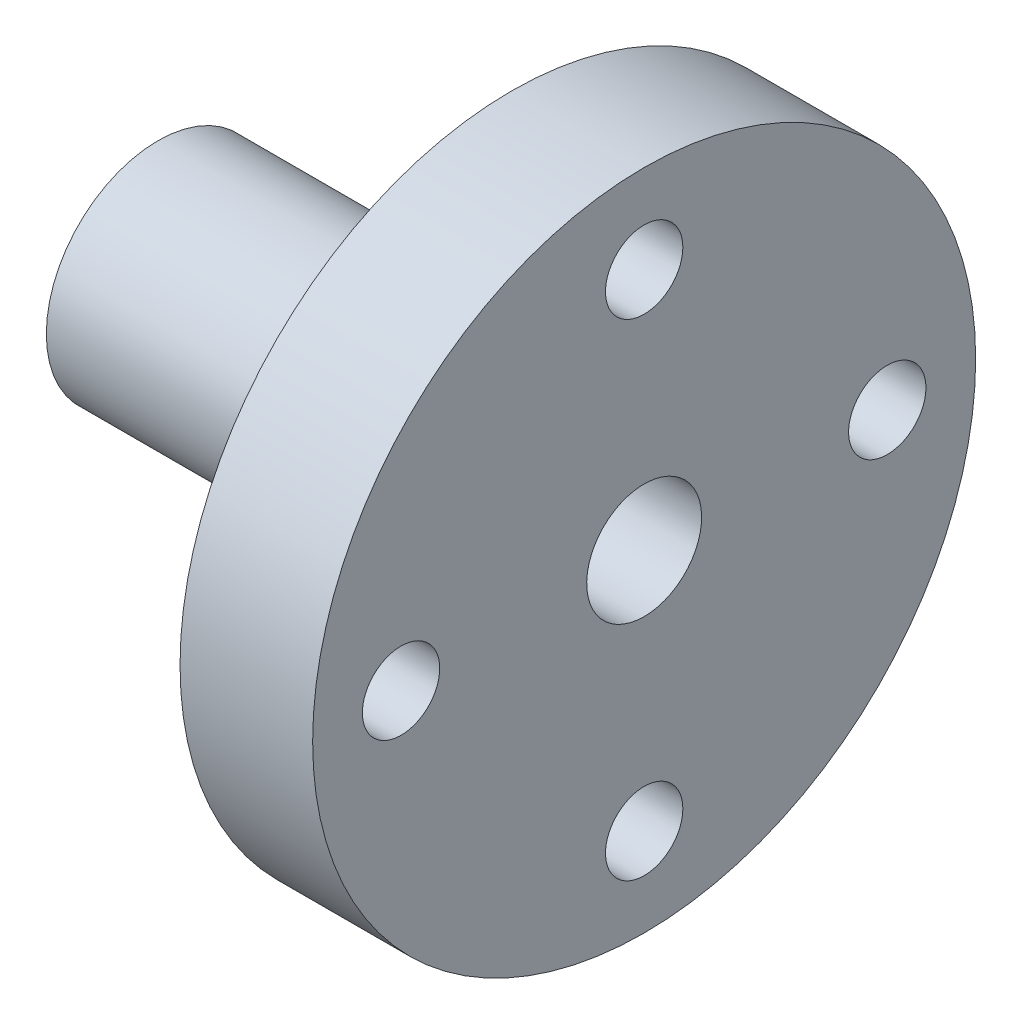
from build123d import *

# Parameters (mm, degrees)
ENL_V_MAT_EXTRU_1_REACH      = 24
ESQUISSE2_R                  = 1.75
ENL_V_MAT_EXTRU_2_DEPTH      = 10
R_P_TITION_CIRCULAIRE1_COUNT = 24


with BuildPart() as part:
    # Esquisse1 → Révolution1 (revolve)
    with BuildSketch(Plane.XY):
        Polygon((0, 2.25), (0, 5.05), (13, 5.05), (13, 8), (16, 8), (16, 15), (22, 15), (22, 2.6), (6, 2.6), (6, 1.2), (3, 1.2), (3, 2.25), align=None)
    revolve(axis=Axis((0, 0, 0), (1, 0, 0)))

    # Esquisse2 → Enlèv. mat.-Extru.1 (cut, up to next)
    with BuildSketch(Plane(origin=(22, 0, 0), x_dir=(0, 0, -1), z_dir=(1, 0, 0)), mode=Mode.PRIVATE) as enl_v_mat_extru_1_sk1:
        with Locations((0, 11)):
            Circle(ESQUISSE2_R)
    enl_v_mat_extru_1_tool1 = extrude(enl_v_mat_extru_1_sk1.sketch, amount=-ENL_V_MAT_EXTRU_1_REACH, mode=Mode.PRIVATE) & part.part
    add(enl_v_mat_extru_1_tool1.solids().sort_by_distance((22, 11, 0))[0], mode=Mode.SUBTRACT)
    # Esquisse2 → Enlèv. mat.-Extru.1 (cut, up to next)
    with BuildSketch(Plane(origin=(22, 0, 0), x_dir=(0, 0, -1), z_dir=(1, 0, 0)), mode=Mode.PRIVATE) as enl_v_mat_extru_1_sk2:
        with Locations((11, 0)):
            Circle(ESQUISSE2_R)
    enl_v_mat_extru_1_tool2 = extrude(enl_v_mat_extru_1_sk2.sketch, amount=-ENL_V_MAT_EXTRU_1_REACH, mode=Mode.PRIVATE) & part.part
    add(enl_v_mat_extru_1_tool2.solids().sort_by_distance((22, 0, -11))[0], mode=Mode.SUBTRACT)
    # Esquisse2 → Enlèv. mat.-Extru.1 (cut, up to next)
    with BuildSketch(Plane(origin=(22, 0, 0), x_dir=(0, 0, -1), z_dir=(1, 0, 0)), mode=Mode.PRIVATE) as enl_v_mat_extru_1_sk3:
        with Locations((0, -11)):
            Circle(ESQUISSE2_R)
    enl_v_mat_extru_1_tool3 = extrude(enl_v_mat_extru_1_sk3.sketch, amount=-ENL_V_MAT_EXTRU_1_REACH, mode=Mode.PRIVATE) & part.part
    add(enl_v_mat_extru_1_tool3.solids().sort_by_distance((22, -11, 0))[0], mode=Mode.SUBTRACT)
    # Esquisse2 → Enlèv. mat.-Extru.1 (cut, up to next)
    with BuildSketch(Plane(origin=(22, 0, 0), x_dir=(0, 0, -1), z_dir=(1, 0, 0)), mode=Mode.PRIVATE) as enl_v_mat_extru_1_sk4:
        with Locations((-11, 0)):
            Circle(ESQUISSE2_R)
    enl_v_mat_extru_1_tool4 = extrude(enl_v_mat_extru_1_sk4.sketch, amount=-ENL_V_MAT_EXTRU_1_REACH, mode=Mode.PRIVATE) & part.part
    add(enl_v_mat_extru_1_tool4.solids().sort_by_distance((22, 0, 11))[0], mode=Mode.SUBTRACT)

    # Esquisse3 → Enlèv. mat.-Extru.2 (cut)
    with BuildSketch(Plane.ZY.offset(-3)):
        Polygon((2.54609184, 0), (2.163423814, -0.382668026), (2.164412287, 0.381679553), align=None)
    enl_v_mat_extru_2 = extrude(amount=ENL_V_MAT_EXTRU_2_DEPTH, mode=Mode.SUBTRACT)

    # Répétition circulaire1: Enlèv. mat.-Extru.2 ×24 about axis
    r_p_tition_circulaire1_axis = Axis((0, 0, 0), (1, 0, 0))
    for i in range(1, R_P_TITION_CIRCULAIRE1_COUNT):
        add(enl_v_mat_extru_2.rotate(r_p_tition_circulaire1_axis, i * 360 / R_P_TITION_CIRCULAIRE1_COUNT), mode=Mode.SUBTRACT)


solid = part.part
